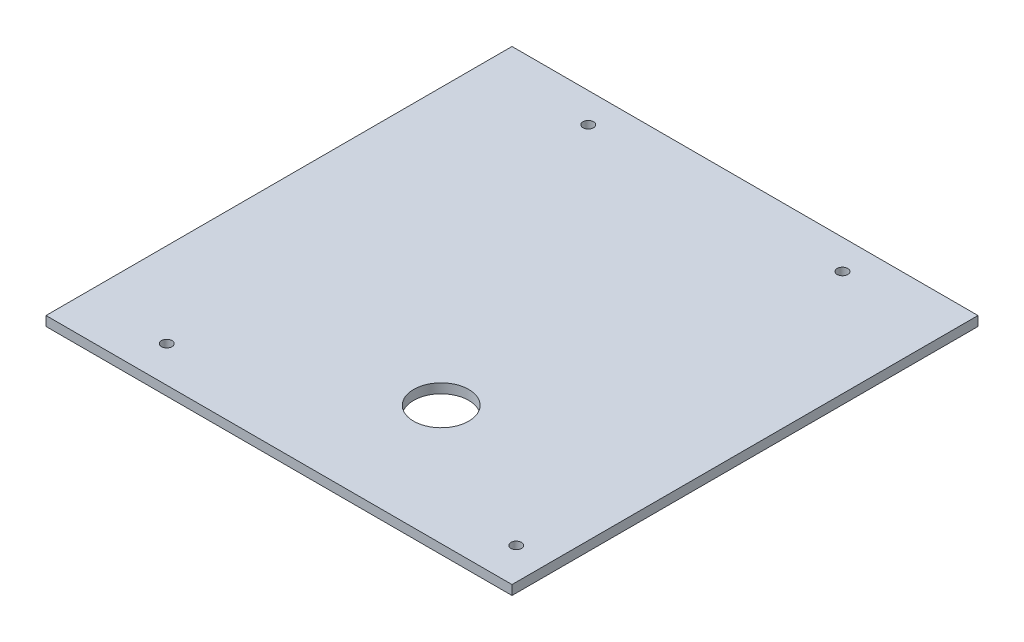
from build123d import *

# Parameters (mm, degrees)
SKETCH1_W           = 220
SKETCH1_H           = 220
BOSS_EXTRUDE1_DEPTH = 4.5
CUT_EXTRUDE1_REACH  = 6.5
SKETCH2_R           = 13
CUT_EXTRUDE2_REACH  = 6.5
SKETCH3_R           = 2.5
CUT_EXTRUDE3_REACH  = 6.5
SKETCH4_R           = 2.5


with BuildPart() as part:
    # Sketch1 → Boss-Extrude1 (new body)
    with BuildSketch(Plane(origin=(0, 0, 0), x_dir=(1, 0, 0), z_dir=(0, 1, 0))):
        Rectangle(SKETCH1_W, SKETCH1_H)
    extrude(amount=BOSS_EXTRUDE1_DEPTH)

    # Sketch2 → Cut-Extrude1 (cut, up to next)
    with BuildSketch(Plane(origin=(0, 4.5, 0), x_dir=(1, 0, 0), z_dir=(0, 1, 0)), mode=Mode.PRIVATE) as cut_extrude1_sk1:
        with Locations((20, -53.431457505)):
            Circle(SKETCH2_R)
    cut_extrude1_tool1 = extrude(cut_extrude1_sk1.sketch, amount=-CUT_EXTRUDE1_REACH, mode=Mode.PRIVATE) & part.part
    add(cut_extrude1_tool1.solids().sort_by_distance((20, 4.5, 53.431458))[0], mode=Mode.SUBTRACT)

    # Sketch3 → Cut-Extrude2 (cut, up to next)
    with BuildSketch(Plane(origin=(0, 4.5, 0), x_dir=(1, 0, 0), z_dir=(0, 1, 0)), mode=Mode.PRIVATE) as cut_extrude2_sk1:
        with Locations((95, -93)):
            Circle(SKETCH3_R)
    cut_extrude2_tool1 = extrude(cut_extrude2_sk1.sketch, amount=-CUT_EXTRUDE2_REACH, mode=Mode.PRIVATE) & part.part
    add(cut_extrude2_tool1.solids().sort_by_distance((95, 4.5, 93))[0], mode=Mode.SUBTRACT)
    # Sketch3 → Cut-Extrude2 (cut, up to next)
    with BuildSketch(Plane(origin=(0, 4.5, 0), x_dir=(1, 0, 0), z_dir=(0, 1, 0)), mode=Mode.PRIVATE) as cut_extrude2_sk2:
        with Locations((-70, -93)):
            Circle(SKETCH3_R)
    cut_extrude2_tool2 = extrude(cut_extrude2_sk2.sketch, amount=-CUT_EXTRUDE2_REACH, mode=Mode.PRIVATE) & part.part
    add(cut_extrude2_tool2.solids().sort_by_distance((-70, 4.5, 93))[0], mode=Mode.SUBTRACT)

    # Sketch4 → Cut-Extrude3 (cut, up to next)
    with BuildSketch(Plane(origin=(0, 0, 0), x_dir=(-1, 0, 0), z_dir=(0, -1, 0)), mode=Mode.PRIVATE) as cut_extrude3_sk1:
        with Locations((-60, 96)):
            Circle(SKETCH4_R)
    cut_extrude3_tool1 = extrude(cut_extrude3_sk1.sketch, amount=-CUT_EXTRUDE3_REACH, mode=Mode.PRIVATE) & part.part
    add(cut_extrude3_tool1.solids().sort_by_distance((60, 0, -96))[0], mode=Mode.SUBTRACT)
    # Sketch4 → Cut-Extrude3 (cut, up to next)
    with BuildSketch(Plane(origin=(0, 0, 0), x_dir=(-1, 0, 0), z_dir=(0, -1, 0)), mode=Mode.PRIVATE) as cut_extrude3_sk2:
        with Locations((60, 96)):
            Circle(SKETCH4_R)
    cut_extrude3_tool2 = extrude(cut_extrude3_sk2.sketch, amount=-CUT_EXTRUDE3_REACH, mode=Mode.PRIVATE) & part.part
    add(cut_extrude3_tool2.solids().sort_by_distance((-60, 0, -96))[0], mode=Mode.SUBTRACT)


solid = part.part
